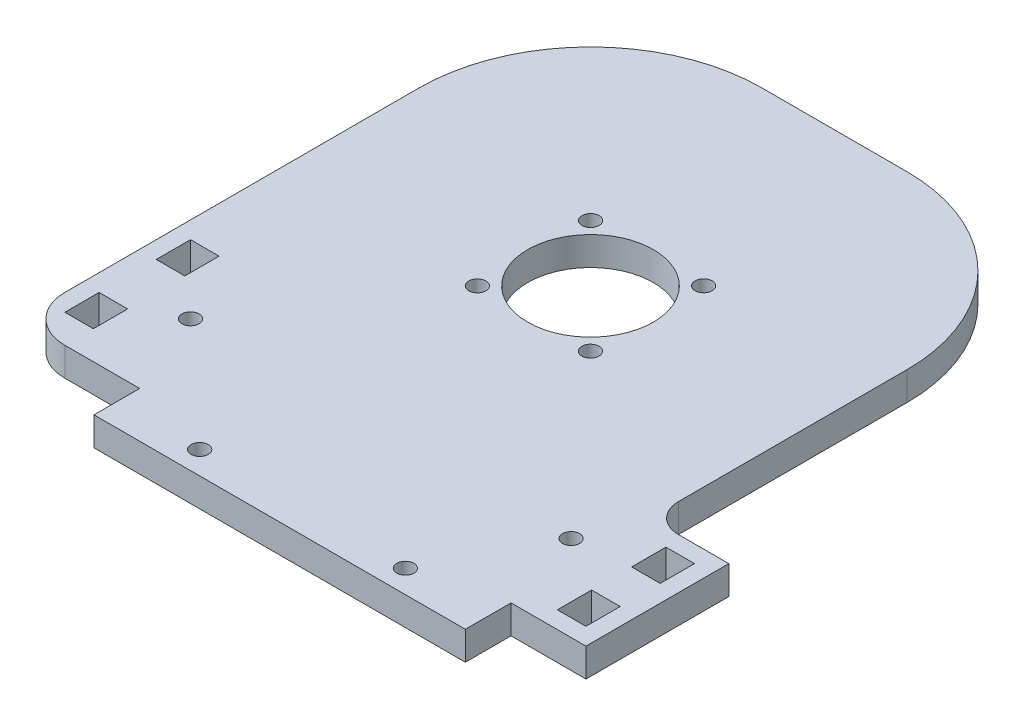
from build123d import *

# Parameters (mm, degrees)
SKETCH1_R           = 11
SKETCH1_R_2         = 1.5
SKETCH1_W           = 5
SKETCH1_H           = 6
BOSS_EXTRUDE1_DEPTH = 5


with BuildPart() as part:
    # Sketch1 → Boss-Extrude1 (new body)
    with BuildSketch(Plane(origin=(0, 0, 0), x_dir=(1, 0, 0), z_dir=(0, 1, 0))):
        with BuildLine():
            Line((40.393958783, 14.993950885), (40.393958783, -25.006049115))
            ThreePointArc((40.393958783, -25.006049115), (41.862698298, -28.539809641), (45.4, -30))
            Line((45.4, -30), (54.2, -30))
            Line((54.2, -30), (54.2, -55))
            Line((54.2, -55), (41.099999997, -55))
            Line((41.099999997, -55), (41.099999997, -63))
            Line((41.099999997, -63), (-23.900000003, -63))
            Line((-23.900000003, -63), (-23.900000003, -55))
            Line((-23.900000003, -55), (-37.00036842, -55))
            ThreePointArc((-37.00036842, -55), (-42.656802211, -52.657122122), (-45.000000024, -47.000820858))
            Line((-45.000000024, -47.000820858), (-45.000000024, 15.001139744))
            ThreePointArc((-45.000000024, 15.001139744), (-36.213537283, 36.213537259), (-15.001139768, 45))
            Line((-15.001139768, 45), (10.397234849, 44.997226593))
            ThreePointArc((10.397234849, 44.997226593), (31.609478673, 36.208113679), (40.393958783, 14.993950885))
        make_face()
        Circle(SKETCH1_R, mode=Mode.SUBTRACT)
        with Locations((9.89288341, 9.906102051)):
            Circle(SKETCH1_R_2, mode=Mode.SUBTRACT)
        with Locations((9.89288341, -9.906102051)):
            Circle(SKETCH1_R_2, mode=Mode.SUBTRACT)
        with Locations((-9.89288341, -9.906102051)):
            Circle(SKETCH1_R_2, mode=Mode.SUBTRACT)
        with Locations((-9.89288341, 9.906102051)):
            Circle(SKETCH1_R_2, mode=Mode.SUBTRACT)
        with Locations((-9.400000003, -59)):
            Circle(SKETCH1_R_2, mode=Mode.SUBTRACT)
        with Locations((26.599999997, -59)):
            Circle(SKETCH1_R_2, mode=Mode.SUBTRACT)
        with Locations((-30.000000024, -40)):
            Circle(SKETCH1_R_2, mode=Mode.SUBTRACT)
        with Locations((36.599999976, -40)):
            Circle(SKETCH1_R_2, mode=Mode.SUBTRACT)
        with Locations((-39.500000024, -31)):
            Rectangle(SKETCH1_W, SKETCH1_H, mode=Mode.SUBTRACT)
        with Locations((-39.500000024, -47)):
            Rectangle(SKETCH1_W, SKETCH1_H, mode=Mode.SUBTRACT)
        with Locations((48.7, -36)):
            Rectangle(SKETCH1_W, SKETCH1_H, mode=Mode.SUBTRACT)
        with Locations((48.7, -49)):
            Rectangle(SKETCH1_W, SKETCH1_H, mode=Mode.SUBTRACT)
    extrude(amount=BOSS_EXTRUDE1_DEPTH)


solid = part.part
